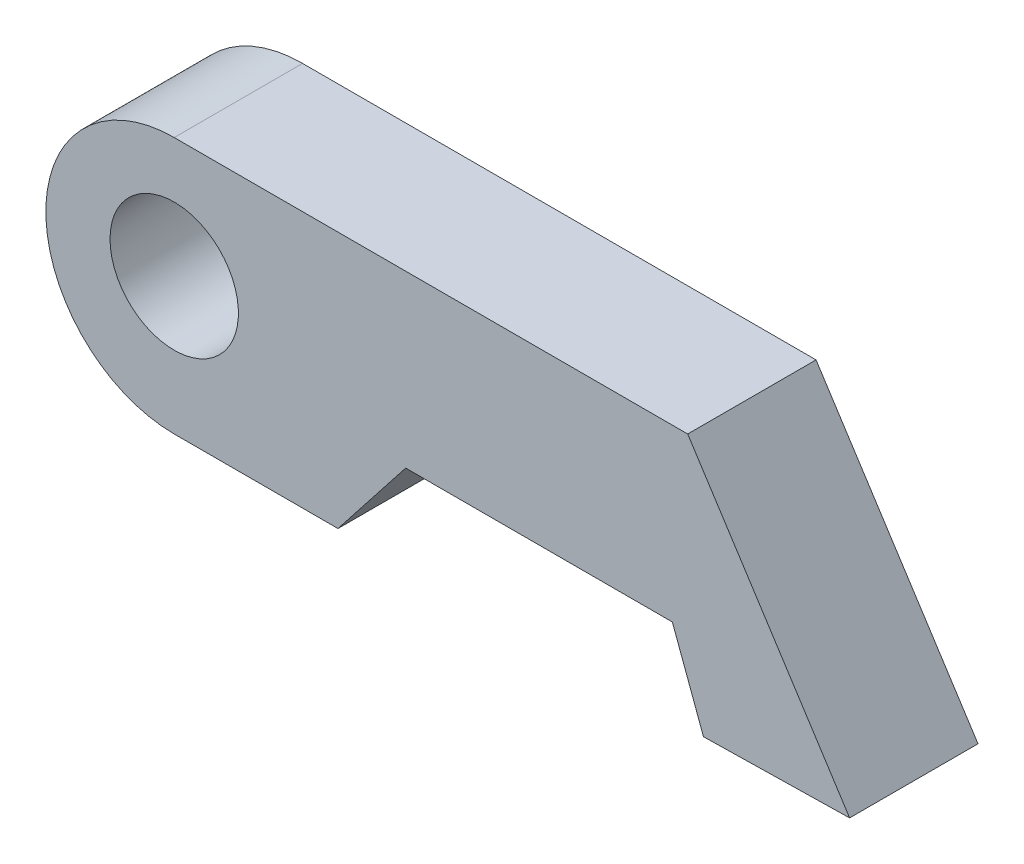
from build123d import *

# Parameters (mm, degrees)
BOSS_EXTRUDE2_DEPTH = 5
CUT_EXTRUDE1_DEPTH  = 5
CUT_EXTRUDE2_DEPTH  = 5
SKETCH7_R           = 2.5
CUT_EXTRUDE3_DEPTH  = 5


with BuildPart() as part:
    # Sketch4 → Boss-Extrude2 (new body)
    with BuildSketch(Plane.XY):
        with BuildLine():
            Line((0, 10), (20, 10))
            Line((20, 10), (26.307466479, 0.203296746))
            Line((26.307466479, 0.203296746), (15.504252616, 0))
            Line((15.504252616, 0), (0, 0))
            ThreePointArc((0, 0), (-5, 5), (0, 10))
        make_face()
    extrude(amount=BOSS_EXTRUDE2_DEPTH)

    # Sketch5 → Cut-Extrude1 (cut)
    with BuildSketch(Plane.XY.offset(5)):
        Polygon((6.379128738, 0), (9.016156307, 3.359284814), (19.402963043, 3.359284814), (20.614889369, 0.096172846), align=None)
    extrude(amount=-CUT_EXTRUDE1_DEPTH, mode=Mode.SUBTRACT)

    # Sketch6 → Cut-Extrude2 (cut)
    with BuildSketch(Plane(origin=(0, 0, 0), x_dir=(-1, 0, 0), z_dir=(0, 0, -1))):
        Polygon((-20.614889369, 0.096172846), (-6.379128738, 0), (-6.379128738, -1.250967918), (-21.241056997, -1.250967918), align=None)
    extrude(amount=-CUT_EXTRUDE2_DEPTH, mode=Mode.SUBTRACT)

    # Sketch7 → Cut-Extrude3 (cut)
    with BuildSketch(Plane(origin=(0, 0, 0), x_dir=(-1, 0, 0), z_dir=(0, 0, -1))):
        with Locations((0, 5.324946676)):
            Circle(SKETCH7_R)
    extrude(amount=-CUT_EXTRUDE3_DEPTH, mode=Mode.SUBTRACT)


solid = part.part
